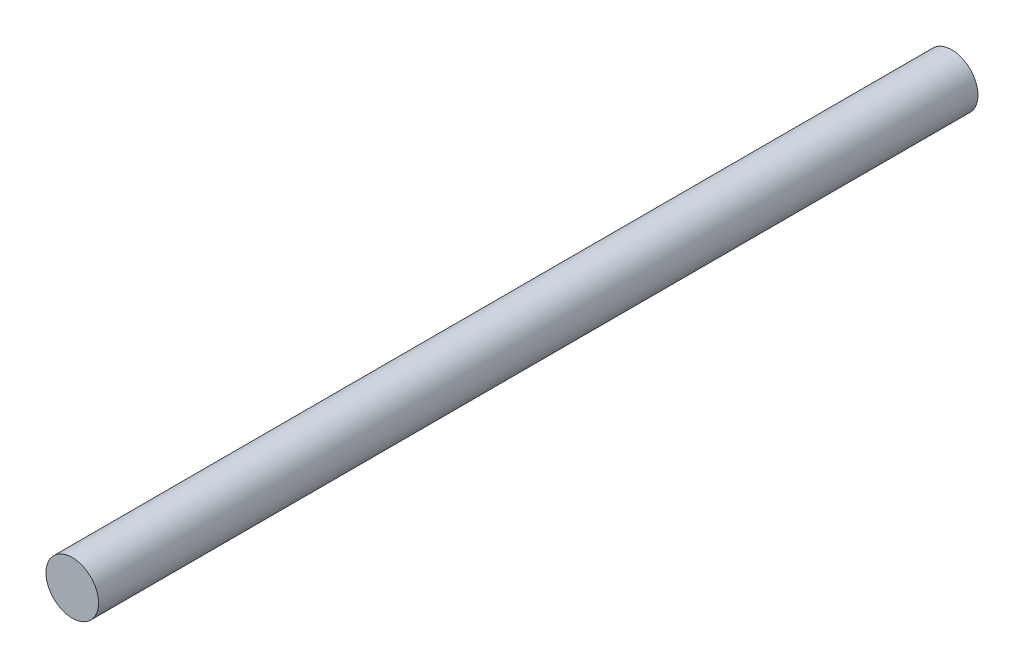
from build123d import *

# Parameters (mm, degrees)
SKETCH1_R           = 3.9878
BOSS_EXTRUDE1_DEPTH = 133.35


with BuildPart() as part:
    # Sketch1 → Boss-Extrude1 (new body)
    with BuildSketch(Plane.XY):
        Circle(SKETCH1_R)
    extrude(amount=BOSS_EXTRUDE1_DEPTH)


solid = part.part
